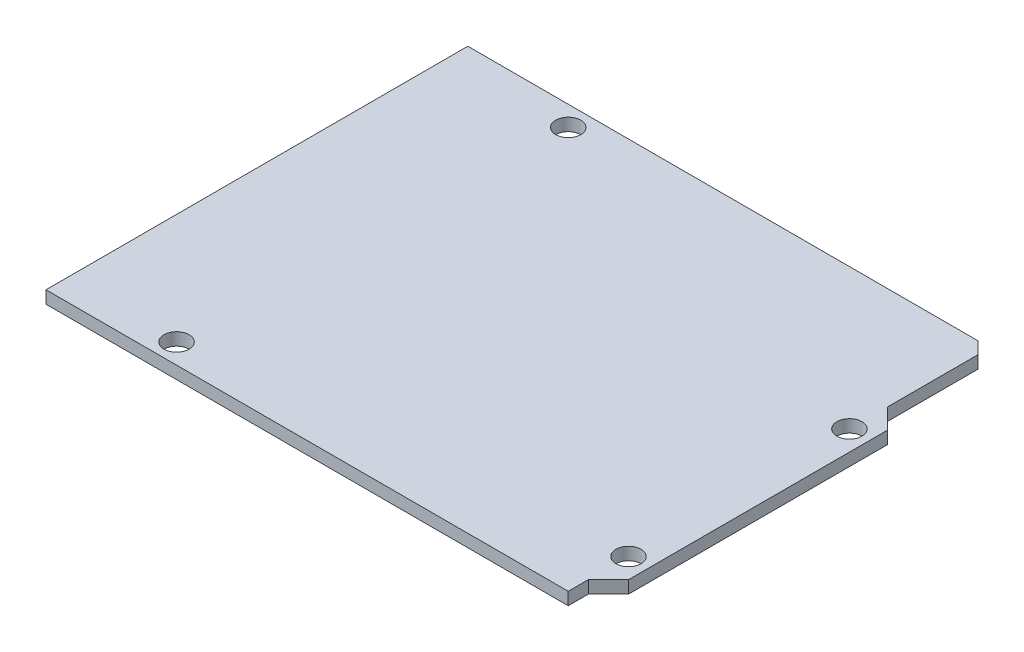
from build123d import *

# Parameters (mm, degrees)
BOSS_EXTRUDE1_DEPTH          = 1.5875
F_1_8_0_125_DIAMETER_HOLE1_D = 3.175


with BuildPart() as part:
    # Sketch1 → Boss-Extrude1 (new body)
    with BuildSketch(Plane(origin=(0, 0, 0), x_dir=(1, 0, 0), z_dir=(0, 1, 0))):
        Polygon((0, 0), (0, 53.34), (64.516, 53.34), (66.04, 51.816), (66.04, 40.386), (68.58, 37.846), (68.58, 5.08), (66.04, 2.54), (66.04, 0), align=None)
    extrude(amount=BOSS_EXTRUDE1_DEPTH)

    # 1/8 (0.125) Diameter Hole1 (through all)
    with Locations(Plane(origin=(0, 1.5875, 0), x_dir=(1, 0, 0), z_dir=(0, 1, 0))):
        with Locations((13.97, 2.54), (15.24, 50.8), (66.04, 35.56), (66.04, 7.62)):
            Hole(F_1_8_0_125_DIAMETER_HOLE1_D / 2)


solid = part.part
